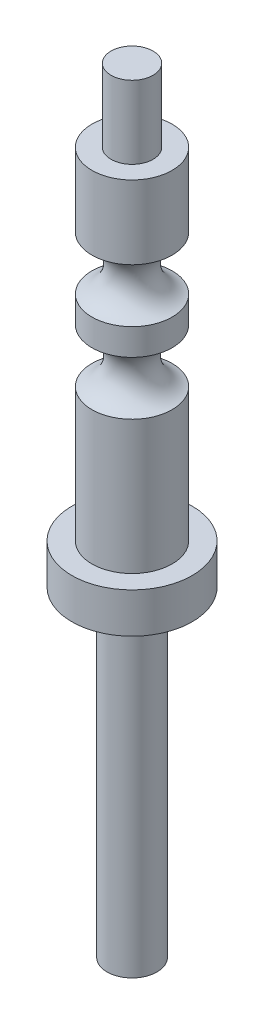
from build123d import *

# Parameters (mm, degrees)
SKETCH2_R           = 4.7625
BOSS_EXTRUDE1_DEPTH = 3.175
LPATTERN1_COUNT     = 2
LPATTERN1_PITCH     = 6.35


with BuildPart() as part:
    # Sketch1 → Revolve1 (revolve)
    with BuildSketch(Plane.XY, mode=Mode.PRIVATE) as revolve1_sk:
        Polygon((0, 0), (1.9812, 0), (1.9812, 25.4), (3.175, 25.4), (3.175, 55.5625), (1.6637, 55.5625), (1.6637, 61.3283), (0, 61.3283), align=None)
    revolve(revolve1_sk.sketch.rotate(Axis((0, 0, 0), (0, 1, 0)), 90), axis=Axis((0, 0, 0), (0, 1, 0)))  # turned: the seam where the file's is

    # Sketch2 → Boss-Extrude1 (add)
    with BuildSketch(Plane.XZ.offset(-25.4)):
        with Locations(Location((0, 0, 0), (0, 0, 270))):  # turned: the seam where the file's is
            Circle(SKETCH2_R)
    extrude(amount=-BOSS_EXTRUDE1_DEPTH)

    # Sketch4 → Cut-Revolve1 (revolve, cut)
    with BuildSketch(Plane(origin=(0, 0, 0), x_dir=(0, 0, -1), z_dir=(1, 0, 0))):
        with BuildLine():
            Line((3.175, 39.1541), (3.175, 43.3959))
            ThreePointArc((3.175, 43.3959), (1.5875, 41.275), (3.175, 39.1541))
        make_face()
    cut_revolve1 = revolve(axis=Axis((0, 0, 0), (0, 1, 0)), mode=Mode.SUBTRACT)

    # LPattern1: Cut-Revolve1 ×2
    with Locations(*[(0, i * LPATTERN1_PITCH, 0) for i in range(1, LPATTERN1_COUNT)]):
        add(cut_revolve1, mode=Mode.SUBTRACT)


solid = part.part
